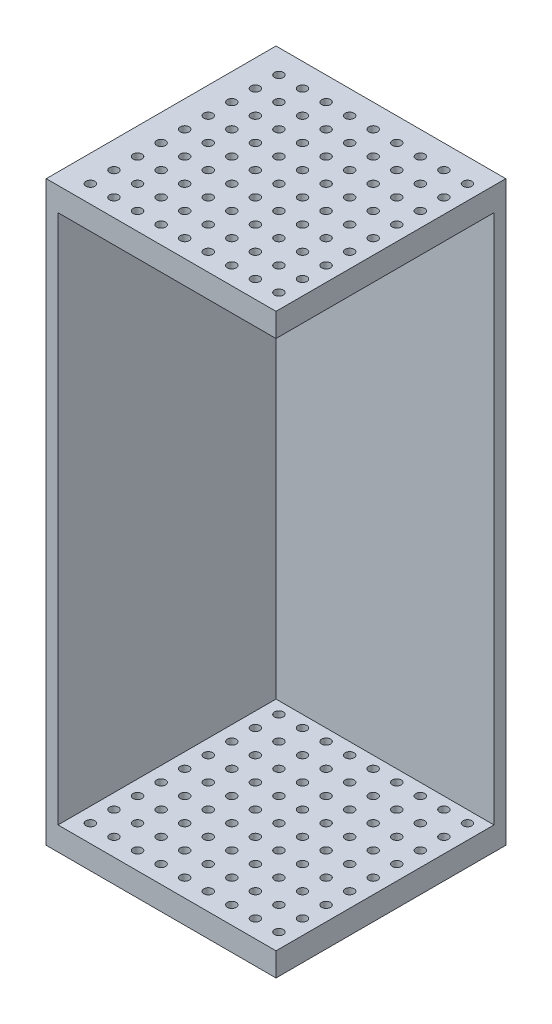
from build123d import *

# Parameters (mm, degrees)
SKETCH1_W           = 19.5
SKETCH1_H           = 19.5
BOSS_EXTRUDE1_DEPTH = 2
BOSS_EXTRUDE2_DEPTH = 45
SKETCH5_W           = 19.5
SKETCH5_H           = 19.5
BOSS_EXTRUDE5_DEPTH = 2
SKETCH3_R           = 0.375
CUT_EXTRUDE1_DEPTH  = 50


with BuildPart() as part:
    # Sketch1 → Boss-Extrude1 (new body)
    with BuildSketch(Plane(origin=(0, 0, 0), x_dir=(1, 0, 0), z_dir=(0, 1, 0))):
        Rectangle(SKETCH1_W, SKETCH1_H)
    extrude(amount=BOSS_EXTRUDE1_DEPTH)

    # Sketch2 → Boss-Extrude2 (add)
    with BuildSketch(Plane(origin=(0, 2, 0), x_dir=(1, 0, 0), z_dir=(0, 1, 0))):
        Polygon((9.75, 8.75), (-8.75, 8.75), (-8.75, -9.75), (-9.75, -9.75), (-9.75, 9.75), (9.75, 9.75), align=None)
    extrude(amount=BOSS_EXTRUDE2_DEPTH)

    # Sketch5 → Boss-Extrude5 (add)
    with BuildSketch(Plane(origin=(0, 47, 0), x_dir=(1, 0, 0), z_dir=(0, 1, 0))):
        Rectangle(SKETCH5_W, SKETCH5_H)
    extrude(amount=BOSS_EXTRUDE5_DEPTH)

    # Sketch3 → Cut-Extrude1 (cut, through all)
    with BuildSketch(Plane.XZ):
        with Locations((-7.5, 8.25)):
            Circle(SKETCH3_R)
        with Locations((-5.5, 8.25)):
            Circle(SKETCH3_R)
        with Locations((-3.5, 8.25)):
            Circle(SKETCH3_R)
        with Locations((-1.5, 8.25)):
            Circle(SKETCH3_R)
        with Locations((0.5, 8.25)):
            Circle(SKETCH3_R)
        with Locations((2.5, 8.25)):
            Circle(SKETCH3_R)
        with Locations((4.5, 8.25)):
            Circle(SKETCH3_R)
        with Locations((6.5, 8.25)):
            Circle(SKETCH3_R)
        with Locations((8.5, 8.25)):
            Circle(SKETCH3_R)
        with Locations((-5.5, 6.25)):
            Circle(SKETCH3_R)
        with Locations((-3.5, 6.25)):
            Circle(SKETCH3_R)
        with Locations((-1.5, 6.25)):
            Circle(SKETCH3_R)
        with Locations((0.5, 6.25)):
            Circle(SKETCH3_R)
        with Locations((2.5, 6.25)):
            Circle(SKETCH3_R)
        with Locations((4.5, 6.25)):
            Circle(SKETCH3_R)
        with Locations((6.5, 6.25)):
            Circle(SKETCH3_R)
        with Locations((8.5, 6.25)):
            Circle(SKETCH3_R)
        with Locations((-5.5, 4.25)):
            Circle(SKETCH3_R)
        with Locations((-3.5, 4.25)):
            Circle(SKETCH3_R)
        with Locations((-1.5, 4.25)):
            Circle(SKETCH3_R)
        with Locations((0.5, 4.25)):
            Circle(SKETCH3_R)
        with Locations((2.5, 4.25)):
            Circle(SKETCH3_R)
        with Locations((4.5, 4.25)):
            Circle(SKETCH3_R)
        with Locations((6.5, 4.25)):
            Circle(SKETCH3_R)
        with Locations((8.5, 4.25)):
            Circle(SKETCH3_R)
        with Locations((-5.5, 2.25)):
            Circle(SKETCH3_R)
        with Locations((-3.5, 2.25)):
            Circle(SKETCH3_R)
        with Locations((-1.5, 2.25)):
            Circle(SKETCH3_R)
        with Locations((0.5, 2.25)):
            Circle(SKETCH3_R)
        with Locations((2.5, 2.25)):
            Circle(SKETCH3_R)
        with Locations((4.5, 2.25)):
            Circle(SKETCH3_R)
        with Locations((6.5, 2.25)):
            Circle(SKETCH3_R)
        with Locations((8.5, 2.25)):
            Circle(SKETCH3_R)
        with Locations((-5.5, 0.25)):
            Circle(SKETCH3_R)
        with Locations((-3.5, 0.25)):
            Circle(SKETCH3_R)
        with Locations((-1.5, 0.25)):
            Circle(SKETCH3_R)
        with Locations((0.5, 0.25)):
            Circle(SKETCH3_R)
        with Locations((2.5, 0.25)):
            Circle(SKETCH3_R)
        with Locations((4.5, 0.25)):
            Circle(SKETCH3_R)
        with Locations((6.5, 0.25)):
            Circle(SKETCH3_R)
        with Locations((8.5, 0.25)):
            Circle(SKETCH3_R)
        with Locations((-5.5, -1.75)):
            Circle(SKETCH3_R)
        with Locations((-3.5, -1.75)):
            Circle(SKETCH3_R)
        with Locations((-1.5, -1.75)):
            Circle(SKETCH3_R)
        with Locations((0.5, -1.75)):
            Circle(SKETCH3_R)
        with Locations((2.5, -1.75)):
            Circle(SKETCH3_R)
        with Locations((4.5, -1.75)):
            Circle(SKETCH3_R)
        with Locations((6.5, -1.75)):
            Circle(SKETCH3_R)
        with Locations((8.5, -1.75)):
            Circle(SKETCH3_R)
        with Locations((-5.5, -3.75)):
            Circle(SKETCH3_R)
        with Locations((-3.5, -3.75)):
            Circle(SKETCH3_R)
        with Locations((-1.5, -3.75)):
            Circle(SKETCH3_R)
        with Locations((0.5, -3.75)):
            Circle(SKETCH3_R)
        with Locations((2.5, -3.75)):
            Circle(SKETCH3_R)
        with Locations((4.5, -3.75)):
            Circle(SKETCH3_R)
        with Locations((6.5, -3.75)):
            Circle(SKETCH3_R)
        with Locations((8.5, -3.75)):
            Circle(SKETCH3_R)
        with Locations((-5.5, -5.75)):
            Circle(SKETCH3_R)
        with Locations((-3.5, -5.75)):
            Circle(SKETCH3_R)
        with Locations((-1.5, -5.75)):
            Circle(SKETCH3_R)
        with Locations((0.5, -5.75)):
            Circle(SKETCH3_R)
        with Locations((2.5, -5.75)):
            Circle(SKETCH3_R)
        with Locations((4.5, -5.75)):
            Circle(SKETCH3_R)
        with Locations((6.5, -5.75)):
            Circle(SKETCH3_R)
        with Locations((8.5, -5.75)):
            Circle(SKETCH3_R)
        with Locations((-5.5, -7.75)):
            Circle(SKETCH3_R)
        with Locations((-3.5, -7.75)):
            Circle(SKETCH3_R)
        with Locations((-1.5, -7.75)):
            Circle(SKETCH3_R)
        with Locations((0.5, -7.75)):
            Circle(SKETCH3_R)
        with Locations((2.5, -7.75)):
            Circle(SKETCH3_R)
        with Locations((4.5, -7.75)):
            Circle(SKETCH3_R)
        with Locations((6.5, -7.75)):
            Circle(SKETCH3_R)
        with Locations((8.5, -7.75)):
            Circle(SKETCH3_R)
        with Locations((-7.5, 6.25)):
            Circle(SKETCH3_R)
        with Locations((-7.5, 4.25)):
            Circle(SKETCH3_R)
        with Locations((-7.5, 2.25)):
            Circle(SKETCH3_R)
        with Locations((-7.5, 0.25)):
            Circle(SKETCH3_R)
        with Locations((-7.5, -1.75)):
            Circle(SKETCH3_R)
        with Locations((-7.5, -3.75)):
            Circle(SKETCH3_R)
        with Locations((-7.5, -5.75)):
            Circle(SKETCH3_R)
        with Locations((-7.5, -7.75)):
            Circle(SKETCH3_R)
    extrude(amount=-CUT_EXTRUDE1_DEPTH, mode=Mode.SUBTRACT)


solid = part.part
